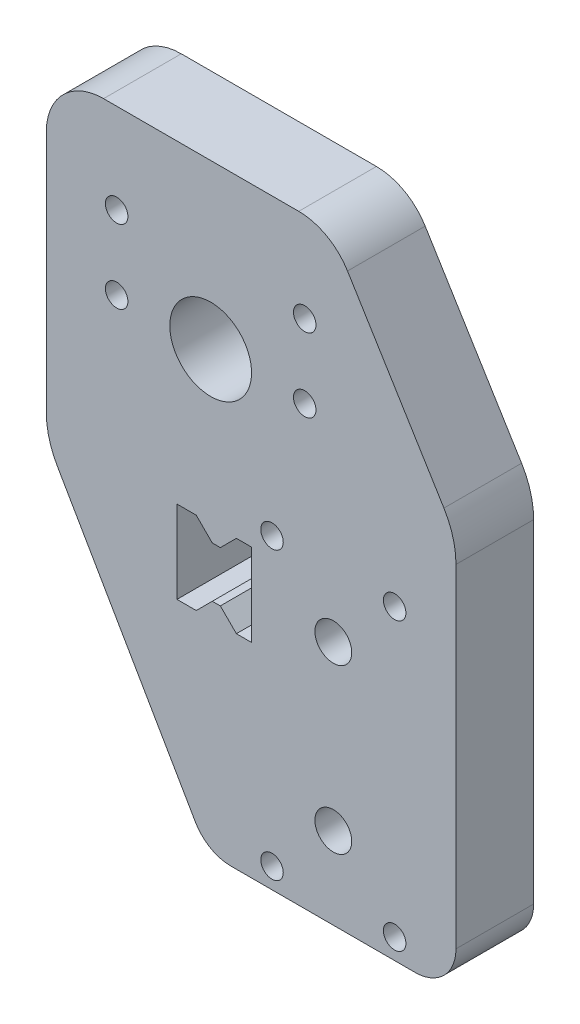
from build123d import *

# Parameters (mm, degrees)
BOSS_EXTRUDE1_DEPTH  = 19
FILLET1_R            = 10
M5_CLEARANCE_HOLE2_D = 5.5
M5_CLEARANCE_HOLE1_D = 5.5
FILLET2_R            = 4
BOSS_EXTRUDE2_DEPTH  = 19
M8_CLEARANCE_HOLE1_D = 9
CUT_EXTRUDE2_DEPTH   = 4
SKETCH16_R           = 10
CUT_EXTRUDE3_DEPTH   = 5
CUT_EXTRUDE4_DEPTH   = 20
SKETCH19_R           = 10
CUT_EXTRUDE5_DEPTH   = 20


with BuildPart() as part:
    # Sketch1 → Boss-Extrude1 (new body)
    with BuildSketch(Plane.XY):
        with BuildLine():
            Line((-170.200000001, 540.824594888), (-129.309401077, 470))
            Line((-129.309401077, 470), (-93, 470))
            ThreePointArc((-93, 470), (-90.878679656, 470.878679656), (-90, 473))
            Line((-90, 473), (-90, 564.25527297))
            Line((-90, 564.25527297), (-116.225329238, 607))
            Line((-116.225329238, 607), (-170.200000001, 607))
            Line((-170.200000001, 607), (-170.200000001, 540.824594888))
        make_face()
    extrude(amount=BOSS_EXTRUDE1_DEPTH)

    # Fillet1
    fillet1_edges = [part.edges().sort_by_distance(p)[0] for p in [
        (-90, 564.25527297, 9.5),
        (-129.309401077, 470, 9.5),
        (-170.200000001, 540.824594888, 9.5),
    ]]
    fillet(fillet1_edges, radius=FILLET1_R)

    # M5 Clearance Hole2 (through all)
    with Locations(Plane(origin=(0, 0, 0), x_dir=(-1, 0, 0), z_dir=(0, 0, -1))):
        with Locations((117.000000001, 595), (117.000000001, 577), (163.000000001, 577), (163.000000001, 595)):
            Hole(M5_CLEARANCE_HOLE2_D / 2)

    # M5 Clearance Hole1 (through all)
    with Locations(Plane.XY.offset(19)):
        with Locations((-95, 545), (-125, 545), (-125, 475), (-95, 475), (-110, 490), (-110, 530)):
            Hole(M5_CLEARANCE_HOLE1_D / 2)

    # Fillet2
    fillet2_edges = [part.edges().sort_by_distance(p)[0] for p in [
        (-116.225329238, 607, 9.5),
        (-170.200000001, 607, 9.5),
    ]]
    fillet(fillet2_edges, radius=FILLET2_R)

    # Sketch11 → Boss-Extrude2 (add)
    with BuildSketch(Plane.XY.offset(19)):
        with BuildLine():
            ThreePointArc((-143.743157806, 475), (-140.082903769, 471.339745962), (-135.082903769, 470))
            Line((-135.082903769, 470), (-123.535898385, 470))
            ThreePointArc((-123.535898385, 470), (-128.535898385, 471.339745962), (-132.196152423, 475))
            Line((-132.196152423, 475), (-168.860254039, 538.504086813))
            ThreePointArc((-168.860254039, 538.504086813), (-169.859258264, 540.915896362), (-170.200000001, 543.504086813))
            Line((-170.200000001, 543.504086813), (-170.200000001, 603))
            ThreePointArc((-170.200000001, 603), (-169.028427125, 605.828427125), (-166.200000001, 607))
            Line((-166.200000001, 607), (-118.464037729, 607))
            ThreePointArc((-118.464037729, 607), (-116.510482263, 606.490504411), (-115.054590744, 605.091810521))
            Line((-115.054590744, 605.091810521), (-91.476382537, 566.661632408))
            ThreePointArc((-91.476382537, 566.661632408), (-90.37617086, 564.149073659), (-90, 561.432106106))
            Line((-90, 561.432106106), (-90, 473))
            ThreePointArc((-90, 473), (-90.878679656, 470.878679656), (-93, 470))
            Line((-93, 470), (-90, 470))
            ThreePointArc((-90, 470), (-82.928932188, 472.928932188), (-80, 480))
            Line((-80, 480), (-80, 561.432106106))
            ThreePointArc((-80, 561.432106106), (-80.75234172, 566.866041212), (-82.952765074, 571.89115871))
            Line((-82.952765074, 571.89115871), (-106.530973281, 610.321336823))
            ThreePointArc((-106.530973281, 610.321336823), (-111.626593598, 615.216765438), (-118.464037729, 617))
            Line((-118.464037729, 617), (-166.200000001, 617))
            ThreePointArc((-166.200000001, 617), (-176.099494937, 612.899494937), (-180.200000001, 603))
            Line((-180.200000001, 603), (-180.200000001, 543.504086813))
            ThreePointArc((-180.200000001, 543.504086813), (-179.518516526, 538.327705911), (-177.520508076, 533.504086813))
            Line((-177.520508076, 533.504086813), (-143.743157806, 475))
        make_face()
    extrude(amount=-BOSS_EXTRUDE2_DEPTH)

    # M8 Clearance Hole1 (through all)
    with Locations(Plane.XY.offset(19)):
        with Locations((-110, 530), (-110, 490)):
            Hole(M8_CLEARANCE_HOLE1_D / 2)

    # Sketch15 → Cut-Extrude2 (cut)
    with BuildSketch(Plane.XY):
        Polygon((-166.960000001, 579.286307066), (-166.960000001, 574.713692934), (-163.000000001, 572.427385868), (-159.040000001, 574.713692934), (-159.040000001, 579.286307066), (-163.000000001, 581.572614132), align=None)
        Polygon((-120.960000001, 579.286307066), (-120.960000001, 574.713692934), (-117.000000001, 572.427385868), (-113.040000001, 574.713692934), (-113.040000001, 579.286307066), (-117.000000001, 581.572614132), align=None)
        Polygon((-113.040000001, 592.713692934), (-117.000000001, 590.427385868), (-120.960000001, 592.713692934), (-120.960000001, 597.286307066), (-117.000000001, 599.572614132), (-113.040000001, 597.286307066), align=None)
        Polygon((-163.000000001, 590.427385868), (-166.960000001, 592.713692934), (-166.960000001, 597.286307066), (-163.000000001, 599.572614132), (-159.040000001, 597.286307066), (-159.040000001, 592.713692934), align=None)
    extrude(amount=CUT_EXTRUDE2_DEPTH, mode=Mode.SUBTRACT)

    # Sketch16 → Cut-Extrude3 (cut)
    with BuildSketch(Plane(origin=(0, 0, 19), x_dir=(-1, 0, 0), z_dir=(0, 0, -1))):
        with Locations((140.000000001, 577)):
            Circle(SKETCH16_R)
    extrude(amount=CUT_EXTRUDE3_DEPTH, mode=Mode.SUBTRACT)

    # Sketch18 → Cut-Extrude4 (cut)
    with BuildSketch(Plane.XY.offset(19)):
        Polygon((-130, 540.1), (-133.716421356, 540.1), (-137.641421356, 536.175), (-139.608578644, 536.175), (-143.533578644, 540.1), (-148.25, 540.1), (-148.25, 519.9), (-143.533578644, 519.9), (-139.608578644, 523.825), (-137.641421356, 523.825), (-133.716421356, 519.9), (-130, 519.9), align=None)
    extrude(amount=-CUT_EXTRUDE4_DEPTH, mode=Mode.SUBTRACT)

    # Sketch19 → Cut-Extrude5 (cut)
    with BuildSketch(Plane.XY.offset(14)):
        with Locations((-140.000000001, 577)):
            Circle(SKETCH19_R)
    extrude(amount=-CUT_EXTRUDE5_DEPTH, mode=Mode.SUBTRACT)


solid = part.part
